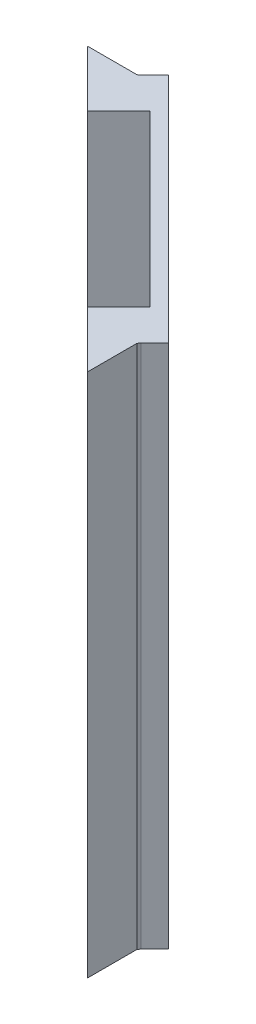
from build123d import *

# Parameters (mm, degrees)
BOSS_EXTRUDE1_DEPTH = 80
SKETCH2_W           = 36.5
SKETCH2_H           = 80
CUT_EXTRUDE1_DEPTH  = 9
SKETCH3_W           = 50
SKETCH3_H           = 80
SKETCH3_W_2         = 25
SKETCH3_H_2         = 72
BOSS_EXTRUDE2_DEPTH = 2


with BuildPart() as part:
    # Sketch1 → Boss-Extrude1 (new body)
    with BuildSketch(Plane(origin=(0, 0, 0), x_dir=(1, 0, 0), z_dir=(0, 1, 0))):
        Polygon((89.086021447, 0.382365888), (91.207341791, 2.503686231), (55.852002731, 37.859025291), (53.730682388, 35.737704947), (53.377128997, 35.487704947), (45.806568717, 35.487704947), (88.836021447, -7.499362096), (88.836021447, 0.028812497), align=None)
    extrude(amount=BOSS_EXTRUDE1_DEPTH)

    # Sketch2 → Cut-Extrude1 (cut)
    with BuildSketch(Plane(origin=(46.855514011, 0, -46.855514011), x_dir=(-0.707106781, 0, -0.707106781), z_dir=(0.707106781, 0, -0.707106781))):
        with Locations((-37.722956362, 40)):
            Rectangle(SKETCH2_W, SKETCH2_H)
    extrude(amount=-CUT_EXTRUDE1_DEPTH, mode=Mode.SUBTRACT)

    # Sketch3 → Boss-Extrude2 (add)
    with BuildSketch(Plane(origin=(46.855514011, 0, -46.855514011), x_dir=(-0.707106781, 0, -0.707106781), z_dir=(0.707106781, 0, -0.707106781))):
        with Locations((-37.722956362, 40)):
            Rectangle(SKETCH3_W, SKETCH3_H)
        with Locations((-37.722956362, 40)):
            Rectangle(SKETCH3_W_2, SKETCH3_H_2, mode=Mode.SUBTRACT)
    extrude(amount=-BOSS_EXTRUDE2_DEPTH)


solid = part.part
